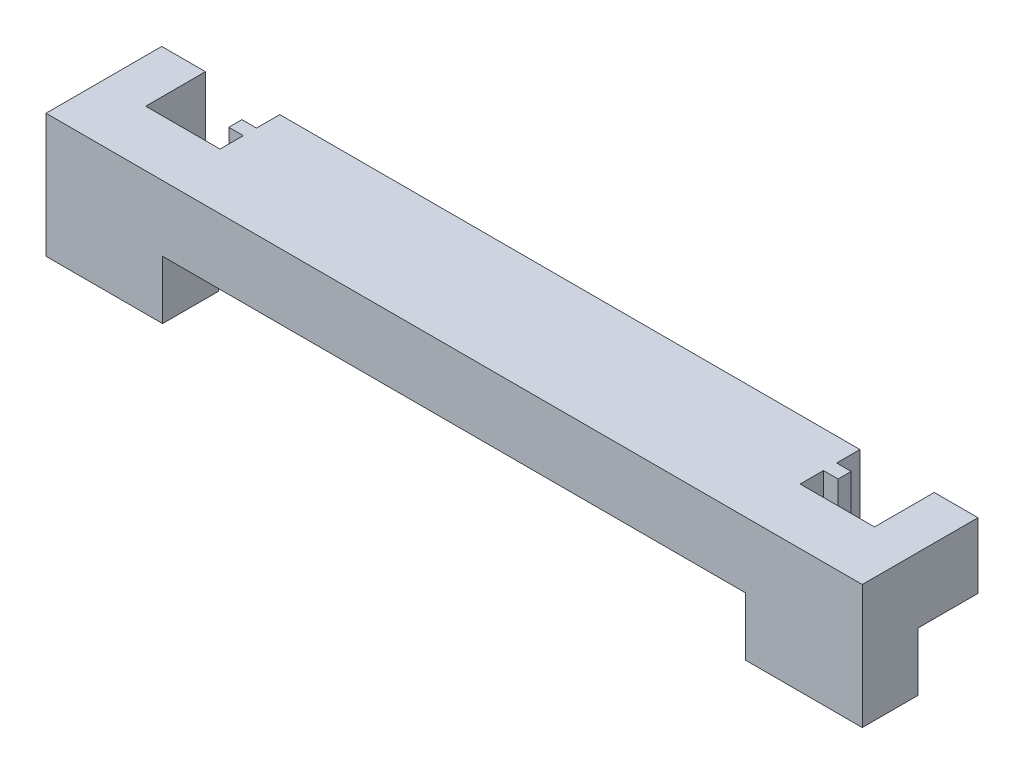
from build123d import *

# Parameters (mm, degrees)
Y_KSEKLIK_EKSTR_ZYON1_DEPTH = 2.25
IZIM5_W                     = 4
IZIM5_H                     = 1.92
Y_KSEKLIK_EKSTR_ZYON4_DEPTH = 2


with BuildPart() as part:
    # Çizim1 → Yükseklik-Ekstrüzyon1 (new body)
    with BuildSketch(Plane(origin=(0, 0, 0), x_dir=(1, 0, 0), z_dir=(0, 1, 0))):
        Polygon((-14, 3.985440092), (-14, 0.015440092), (14, 0.015440092), (14, 3.985440092), (12.5, 3.985440092), (12.5, 1.935440092), (9.95, 1.935440092), (9.95, 2.735440092), (10.45, 2.735440092), (10.45, 3.185440092), (9.95, 3.185440092), (9.95, 3.985440092), (-9.95, 3.985440092), (-9.95, 3.185440092), (-10.45, 3.185440092), (-10.45, 2.735440092), (-9.95, 2.735440092), (-9.95, 1.935440092), (-12.5, 1.935440092), (-12.5, 3.985440092), align=None)
    extrude(amount=Y_KSEKLIK_EKSTR_ZYON1_DEPTH)

    # Çizim5 → Yükseklik-Ekstrüzyon4 (add)
    with BuildSketch(Plane.XZ):
        with Locations((-12, -0.975440092)):
            Rectangle(IZIM5_W, IZIM5_H)
        with Locations((12, -0.975440092)):
            Rectangle(IZIM5_W, IZIM5_H)
    extrude(amount=Y_KSEKLIK_EKSTR_ZYON4_DEPTH)


solid = part.part
